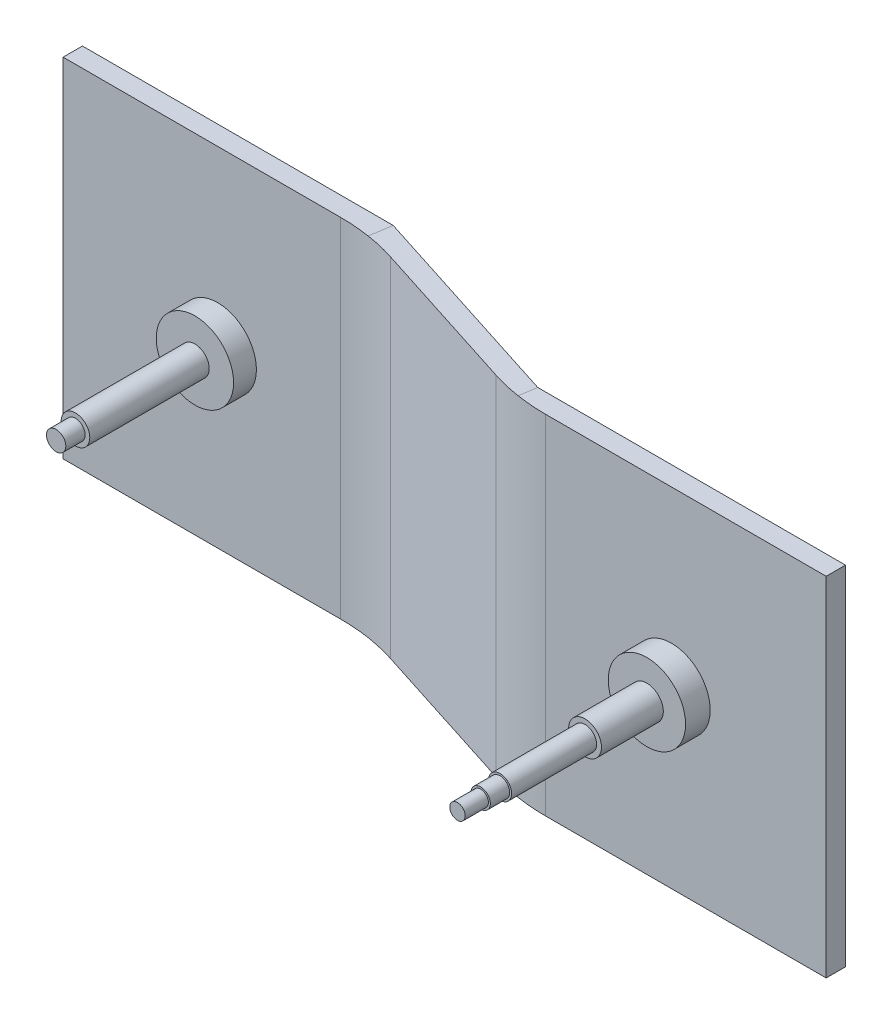
from build123d import *

# Parameters (mm, degrees)
SCHIZZO16_W                   = 10
SCHIZZO16_H                   = 180
SCHIZZO17_R                   = 20
ESTRUSIONE_ESTRUSIONE10_DEPTH = 12.75569081
SCHIZZO18_R                   = 8.5
ESTRUSIONE_ESTRUSIONE11_DEPTH = 32
SCHIZZO19_R                   = 6
ESTRUSIONE_ESTRUSIONE12_DEPTH = 44
SCHIZZO20_R                   = 5
ESTRUSIONE_ESTRUSIONE13_DEPTH = 10
SCHIZZO21_R                   = 4
ESTRUSIONE_ESTRUSIONE14_DEPTH = 12
SCHIZZO22_R                   = 20
ESTRUSIONE_ESTRUSIONE15_DEPTH = 11.80548778
SCHIZZO23_R                   = 7.4
ESTRUSIONE_ESTRUSIONE16_DEPTH = 61.8
SCHIZZO24_R                   = 5
ESTRUSIONE_ESTRUSIONE17_DEPTH = 10
RACCORDO1_R                   = 100


with BuildPart() as part:
    # Sweep1: sweep along a path in Schizzo15
    with BuildLine(Plane(origin=(0, 0, 0), x_dir=(1, 0, 0), z_dir=(0, 1, 0))) as sweep1_path:
        Line((-350, 35.20194684), (-190, 35.20194684))
        Line((-190, 35.20194684), (-80, 0))
        Line((-80, 0), (80, 0))
    # Schizzo16 → Sweep1 (sweep)
    with BuildSketch(Plane(origin=(0, 0, 0), x_dir=(0, 0, -1), z_dir=(1, 0, 0))):
        Rectangle(SCHIZZO16_W, SCHIZZO16_H)
    sweep(path=sweep1_path.line, transition=Transition.RIGHT)

    # Schizzo17 → Estrusione-Estrusione10 (add)
    with BuildSketch(Plane.XY.offset(5)):
        Circle(SCHIZZO17_R)
    extrude(amount=ESTRUSIONE_ESTRUSIONE10_DEPTH)

    # Schizzo18 → Estrusione-Estrusione11 (add)
    with BuildSketch(Plane.XY.offset(17.75569081)):
        Circle(SCHIZZO18_R)
    extrude(amount=ESTRUSIONE_ESTRUSIONE11_DEPTH)

    # Schizzo19 → Estrusione-Estrusione12 (add)
    with BuildSketch(Plane.XY.offset(49.75569081)):
        Circle(SCHIZZO19_R)
    extrude(amount=ESTRUSIONE_ESTRUSIONE12_DEPTH)

    # Schizzo20 → Estrusione-Estrusione13 (add)
    with BuildSketch(Plane.XY.offset(93.75569081)):
        Circle(SCHIZZO20_R)
    extrude(amount=ESTRUSIONE_ESTRUSIONE13_DEPTH)

    # Schizzo21 → Estrusione-Estrusione14 (add)
    with BuildSketch(Plane.XY.offset(103.75569081)):
        Circle(SCHIZZO21_R)
    extrude(amount=ESTRUSIONE_ESTRUSIONE14_DEPTH)

    # Schizzo22 → Estrusione-Estrusione15 (add)
    with BuildSketch(Plane.XY.offset(-30.20194684)):
        with Locations((-270, 0)):
            Circle(SCHIZZO22_R)
    extrude(amount=ESTRUSIONE_ESTRUSIONE15_DEPTH)

    # Schizzo23 → Estrusione-Estrusione16 (add)
    with BuildSketch(Plane.XY.offset(-18.39645906)):
        with Locations((-270, 0)):
            Circle(SCHIZZO23_R)
    extrude(amount=ESTRUSIONE_ESTRUSIONE16_DEPTH)

    # Schizzo24 → Estrusione-Estrusione17 (add)
    with BuildSketch(Plane.XY.offset(43.40354094)):
        with Locations((-270, 0)):
            Circle(SCHIZZO24_R)
    extrude(amount=ESTRUSIONE_ESTRUSIONE17_DEPTH)

    # Raccordo1
    raccordo1_edges = [part.edges().sort_by_distance(p)[0] for p in [
        (-80.78054705, 0, 5),
        (-190.78054705, 0, -30.20194684),
    ]]
    fillet(raccordo1_edges, radius=RACCORDO1_R)


solid = part.part
